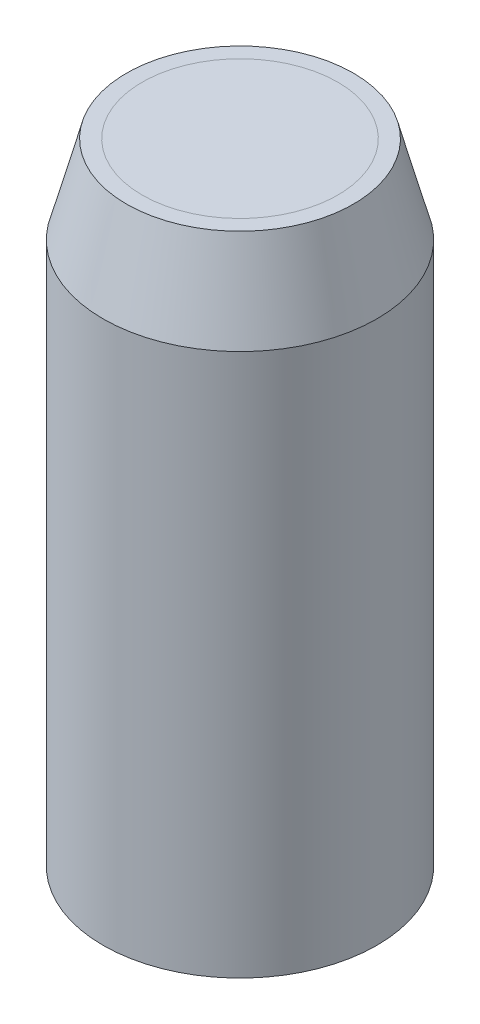
from build123d import *

# Parameters (mm, degrees)
SKETCH1_R           = 5
BOSS_EXTRUDE1_DEPTH = 29.81174009


with BuildPart() as part:
    # Sketch1 → Boss-Extrude1 (new body)
    with BuildSketch(Plane(origin=(0, 0, 0), x_dir=(1, 0, 0), z_dir=(0, 1, 0))):
        Circle(SKETCH1_R)
    extrude(amount=BOSS_EXTRUDE1_DEPTH)


with BuildPart() as body_2:
    # Sketch2 → Revolve1 (revolve)
    with BuildSketch(Plane.XY):
        Polygon((0, 0), (-5, 0), (-5, 29.81174009), (-5.8, 29.81174009), (-7, 25.333279121), (-7, -2.4), (0, -2.4), align=None)
    revolve(axis=Axis((0, 0, 0), (0, 1, 0)))


solid = Compound([part.part, body_2.part])
